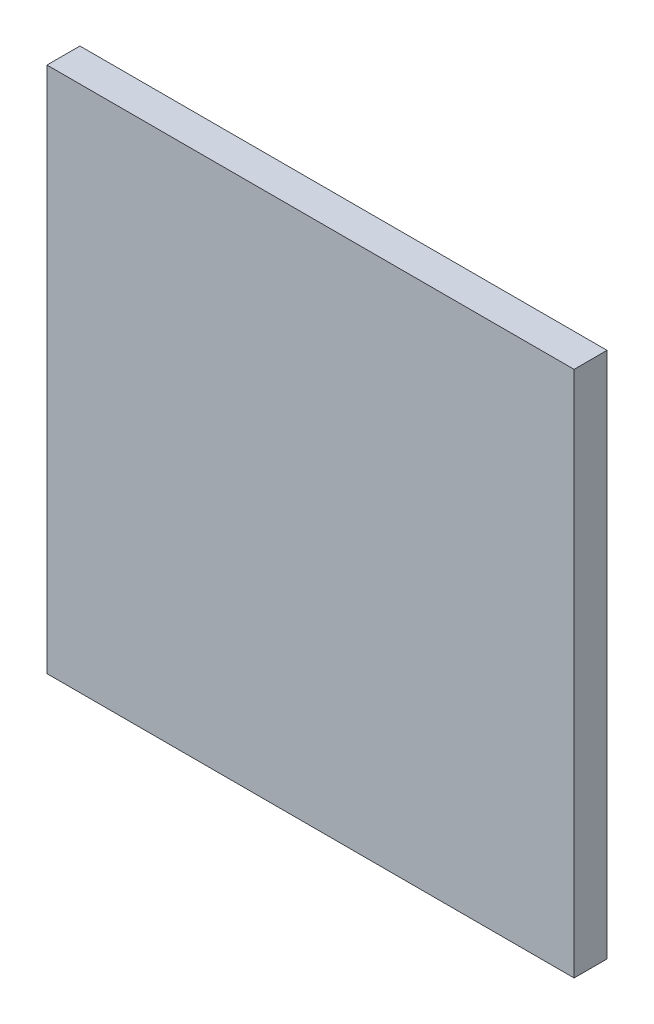
from build123d import *

# Parameters (mm, degrees)
SKETCH1_W           = 40
SKETCH1_H           = 40
BOSS_EXTRUDE1_DEPTH = 2.5


with BuildPart() as part:
    # Sketch1 → Boss-Extrude1 (new body)
    with BuildSketch(Plane.XY):
        with Locations((20, 20)):
            Rectangle(SKETCH1_W, SKETCH1_H)
    extrude(amount=BOSS_EXTRUDE1_DEPTH)


solid = part.part
